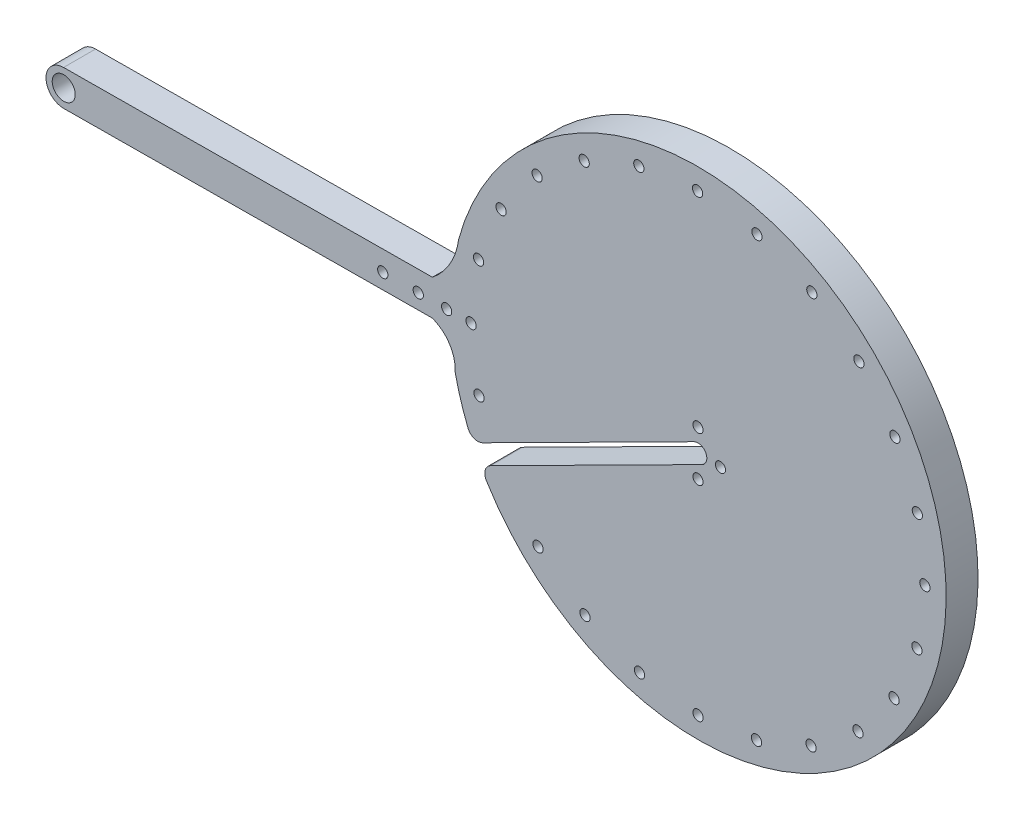
from build123d import *

# Parameters (mm, degrees)
SKETCH1_R           = 1.4225
SKETCH1_R_2         = 1.450000001
SKETCH1_R_3         = 3.250000001
SKETCH1_R_4         = 1.45
BOSS_EXTRUDE2_DEPTH = 9
FILLET1_R           = 3
FILLET2_R           = 3


with BuildPart() as part:
    # Sketch1 → Boss-Extrude2 (new body)
    with BuildSketch(Plane.XY):
        with BuildLine():
            Line((-134.22032992, 11.211856555), (-30.257718346, 11.989277985))
            ThreePointArc((-30.257718346, 11.989277985), (-25.422812351, 8.063130211), (-23.849365383, 2.036919381))
            ThreePointArc((-23.849365383, 2.036919381), (-21.809168303, -5.524545992), (-18.937059892, -12.810776569))
            Line((-18.937059892, -12.810776569), (43.522166186, 18.694700379))
            ThreePointArc((43.522166186, 18.694700379), (46.880190718, 17.588503631), (45.77399397, 14.230479099))
            Line((45.77399397, 14.230479099), (-16.685232108, -17.274997849))
            ThreePointArc((-16.685232108, -17.274997849), (60.631470485, -51.68820799), (114.585866087, 13.511981637))
            ThreePointArc((114.585866087, 13.511981637), (55.491058325, 85.617703959), (-22.83660712, 35.058745089))
            ThreePointArc((-22.83660712, 35.058745089), (-25.272857454, 27.800559204), (-30.257718346, 21.989557576))
            Line((-30.257718346, 21.989557576), (-134.295106773, 21.211576972))
            ThreePointArc((-134.295106773, 21.211576972), (-139.257578555, 16.174328337), (-134.22032992, 11.211856555))
        make_face()
        with Locations((44.661222783, 22.812576138)):
            Circle(SKETCH1_R, mode=Mode.SUBTRACT)
        with Locations((-17.105082345, -0.346542621)):
            Circle(SKETCH1_R_2, mode=Mode.SUBTRACT)
        with Locations((-134.257718346, 16.211716764)):
            Circle(SKETCH1_R_3, mode=Mode.SUBTRACT)
        with Locations((-17.234763001, 32.78783805)):
            Circle(SKETCH1_R_2, mode=Mode.SUBTRACT)
        with Locations((-10.886578119, 48.272992738)):
            Circle(SKETCH1_R_2, mode=Mode.SUBTRACT)
        with Locations((-19.351394551, 16.203268944)):
            Circle(SKETCH1_R_2, mode=Mode.SUBTRACT)
        with Locations((-44.257717657, 16.208005084)):
            Circle(SKETCH1_R_4, mode=Mode.SUBTRACT)
        with Locations((-34.257718346, 16.211716764)):
            Circle(SKETCH1_R_4, mode=Mode.SUBTRACT)
        with Locations((-26.257718346, 16.211716764)):
            Circle(SKETCH1_R_4, mode=Mode.SUBTRACT)
        with Locations((50.992814526, 16.20404615)):
            Circle(SKETCH1_R, mode=Mode.SUBTRACT)
        with Locations((44.66019165, 10.112601289)):
            Circle(SKETCH1_R, mode=Mode.SUBTRACT)
        with Locations((106.402979176, -0.340161148)):
            Circle(SKETCH1_R_2, mode=Mode.SUBTRACT)
        with Locations((99.964508374, -15.725805073)):
            Circle(SKETCH1_R_2, mode=Mode.SUBTRACT)
        with Locations((89.779783974, -28.915040251)):
            Circle(SKETCH1_R_2, mode=Mode.SUBTRACT)
        with Locations((76.545581676, -39.022087351)):
            Circle(SKETCH1_R_2, mode=Mode.SUBTRACT)
        with Locations((61.159646121, -45.37080081)):
            Circle(SKETCH1_R_2, mode=Mode.SUBTRACT)
        with Locations((44.660635327, -47.53740903)):
            Circle(SKETCH1_R_2, mode=Mode.SUBTRACT)
        with Locations((28.159958748, -45.377056565)):
            Circle(SKETCH1_R_2, mode=Mode.SUBTRACT)
        with Locations((12.769465369, -39.03294093)):
            Circle(SKETCH1_R_2, mode=Mode.SUBTRACT)
        with Locations((-0.470981954, -28.927610099)):
            Circle(SKETCH1_R_2, mode=Mode.SUBTRACT)
        with Locations((-0.73028884, 61.593550668)):
            Circle(SKETCH1_R_2, mode=Mode.SUBTRACT)
        with Locations((12.544950118, 71.828545405)):
            Circle(SKETCH1_R_2, mode=Mode.SUBTRACT)
        with Locations((27.96860152, 78.250897654)):
            Circle(SKETCH1_R_2, mode=Mode.SUBTRACT)
        with Locations((44.528931823, 80.46247883)):
            Circle(SKETCH1_R_2, mode=Mode.SUBTRACT)
        with Locations((61.289362626, 78.261195833)):
            Circle(SKETCH1_R_2, mode=Mode.SUBTRACT)
        with Locations((76.770141151, 71.817564153)):
            Circle(SKETCH1_R_2, mode=Mode.SUBTRACT)
        with Locations((90.039018635, 61.580908601)):
            Circle(SKETCH1_R_2, mode=Mode.SUBTRACT)
        with Locations((100.202860624, 48.237837315)):
            Circle(SKETCH1_R_2, mode=Mode.SUBTRACT)
        with Locations((106.533916616, 32.776486758)):
            Circle(SKETCH1_R_2, mode=Mode.SUBTRACT)
        with Locations((108.64755512, 16.203371079)):
            Circle(SKETCH1_R_2, mode=Mode.SUBTRACT)
    extrude(amount=BOSS_EXTRUDE2_DEPTH)

    # Fillet1
    fillet1_edges = [part.edges().sort_by_distance(p)[0] for p in [
        (-18.937059892, -12.810776569, 4.5),
    ]]
    fillet(fillet1_edges, radius=FILLET1_R)

    # Fillet2
    fillet2_edges = [part.edges().sort_by_distance(p)[0] for p in [
        (-16.685232108, -17.274997849, 4.5),
    ]]
    fillet(fillet2_edges, radius=FILLET2_R)


solid = part.part
